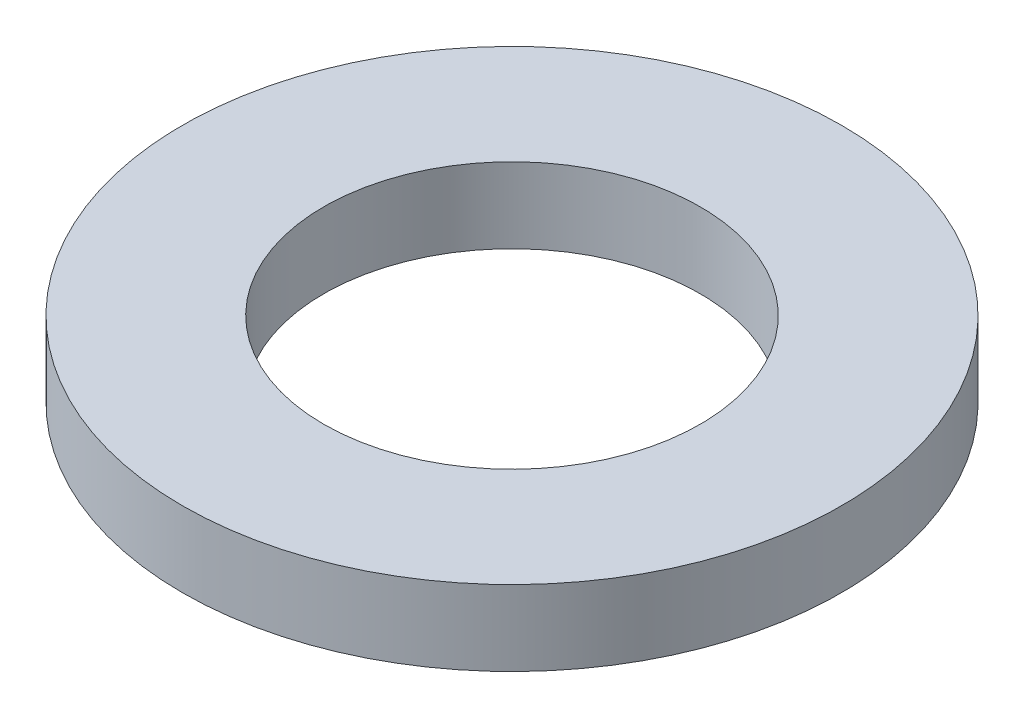
from build123d import *

# Parameters (mm, degrees)
SKETCH1_R           = 17.5
SKETCH1_R_2         = 10
BOSS_EXTRUDE1_DEPTH = 4


with BuildPart() as part:
    # Sketch1 → Boss-Extrude1 (new body)
    with BuildSketch(Plane(origin=(0, 0, 0), x_dir=(1, 0, 0), z_dir=(0, 1, 0))):
        Circle(SKETCH1_R)
        Circle(SKETCH1_R_2, mode=Mode.SUBTRACT)
    extrude(amount=BOSS_EXTRUDE1_DEPTH)


solid = part.part
